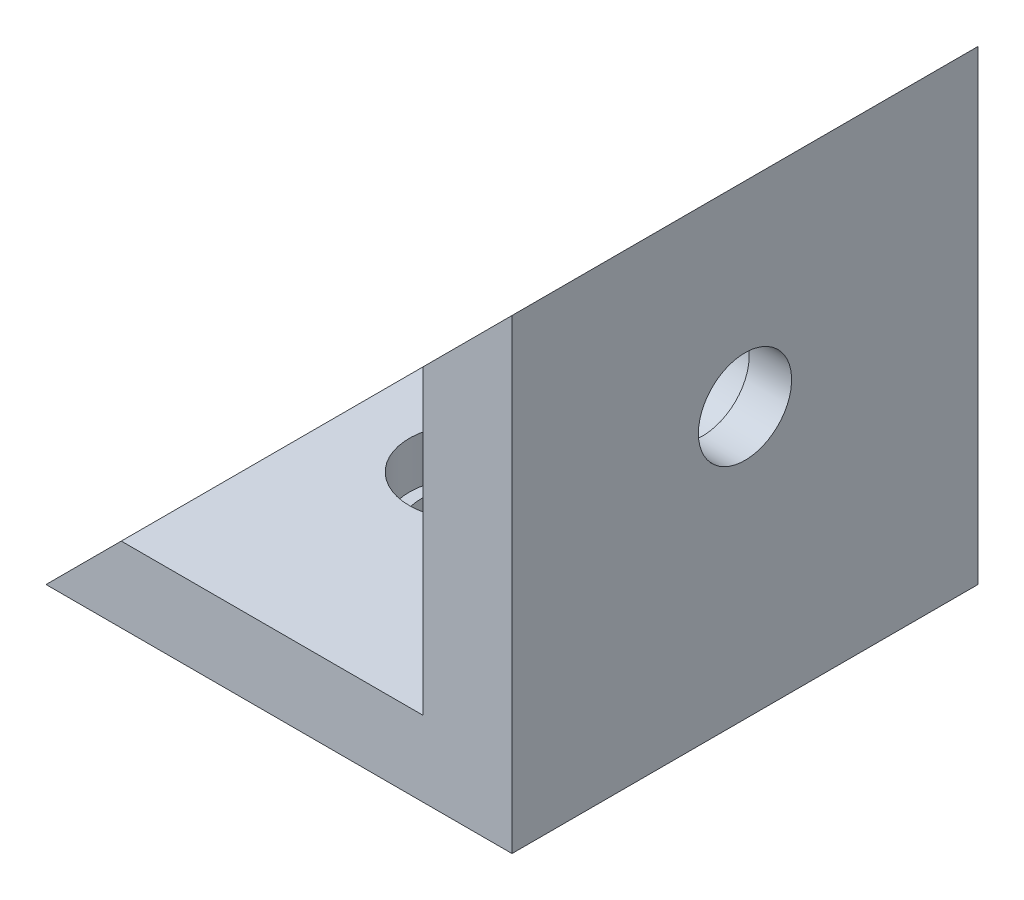
from build123d import *

# Parameters (mm, degrees)
IZIM1_W                     = 20
IZIM1_H                     = 20
Y_KSEKLIK_EKSTR_ZYON1_DEPTH = 20
KES_EKSTR_ZYON1_DEPTH       = 20
IZIM3_W                     = 17.224679165
IZIM3_H                     = 17.248412117
KES_EKSTR_ZYON2_DEPTH       = 20
IZIM4_R                     = 2
KES_EKSTR_ZYON3_DEPTH       = 20
IZIM7_R                     = 2.5
KES_EKSTR_ZYON7_DEPTH       = 2
IZIM8_R                     = 2
KES_EKSTR_ZYON8_DEPTH       = 10
IZIM9_R                     = 2.5
KES_EKSTR_ZYON9_DEPTH       = 2


with BuildPart() as part:
    # Çizim1 → Yükseklik-Ekstrüzyon1 (new body)
    with BuildSketch(Plane.XY):
        with Locations((-13.172756411, -5.622082974)):
            Rectangle(IZIM1_W, IZIM1_H)
    extrude(amount=Y_KSEKLIK_EKSTR_ZYON1_DEPTH)

    # Çizim2 → Kes-Ekstrüzyon1 (cut)
    with BuildSketch(Plane.XY.offset(20)):
        Polygon((-3.172756411, 4.377917026), (-23.172756411, -15.622082974), (-23.172756411, 4.377917026), align=None)
    extrude(amount=-KES_EKSTR_ZYON1_DEPTH, mode=Mode.SUBTRACT)

    # Çizim3 → Kes-Ekstrüzyon2 (cut)
    with BuildSketch(Plane.XY.offset(20)):
        with Locations((-15.601705124, -3.767784851)):
            Rectangle(IZIM3_W, IZIM3_H)
    extrude(amount=-KES_EKSTR_ZYON2_DEPTH, mode=Mode.SUBTRACT)

    # Çizim4 → Kes-Ekstrüzyon3 (cut)
    with BuildSketch(Plane.ZY.offset(6.989365541)):
        with Locations((10, -4.007036941)):
            Circle(IZIM4_R)
    extrude(amount=-KES_EKSTR_ZYON3_DEPTH, mode=Mode.SUBTRACT)

    # Çizim7 → Kes-Ekstrüzyon7 (cut)
    with BuildSketch(Plane.ZY.offset(6.989365541)):
        with Locations((10, -4.007036941)):
            Circle(IZIM7_R)
    extrude(amount=-KES_EKSTR_ZYON7_DEPTH, mode=Mode.SUBTRACT)

    # Çizim8 → Kes-Ekstrüzyon8 (cut)
    with BuildSketch(Plane(origin=(0, -12.391990909, 0), x_dir=(1, 0, 0), z_dir=(0, 1, 0))):
        with Locations((-15.081060976, -10)):
            Circle(IZIM8_R)
    extrude(amount=-KES_EKSTR_ZYON8_DEPTH, mode=Mode.SUBTRACT)

    # Çizim9 → Kes-Ekstrüzyon9 (cut)
    with BuildSketch(Plane(origin=(0, -12.391990909, 0), x_dir=(1, 0, 0), z_dir=(0, 1, 0))):
        with Locations((-15.081060976, -10)):
            Circle(IZIM9_R)
    extrude(amount=-KES_EKSTR_ZYON9_DEPTH, mode=Mode.SUBTRACT)


solid = part.part
